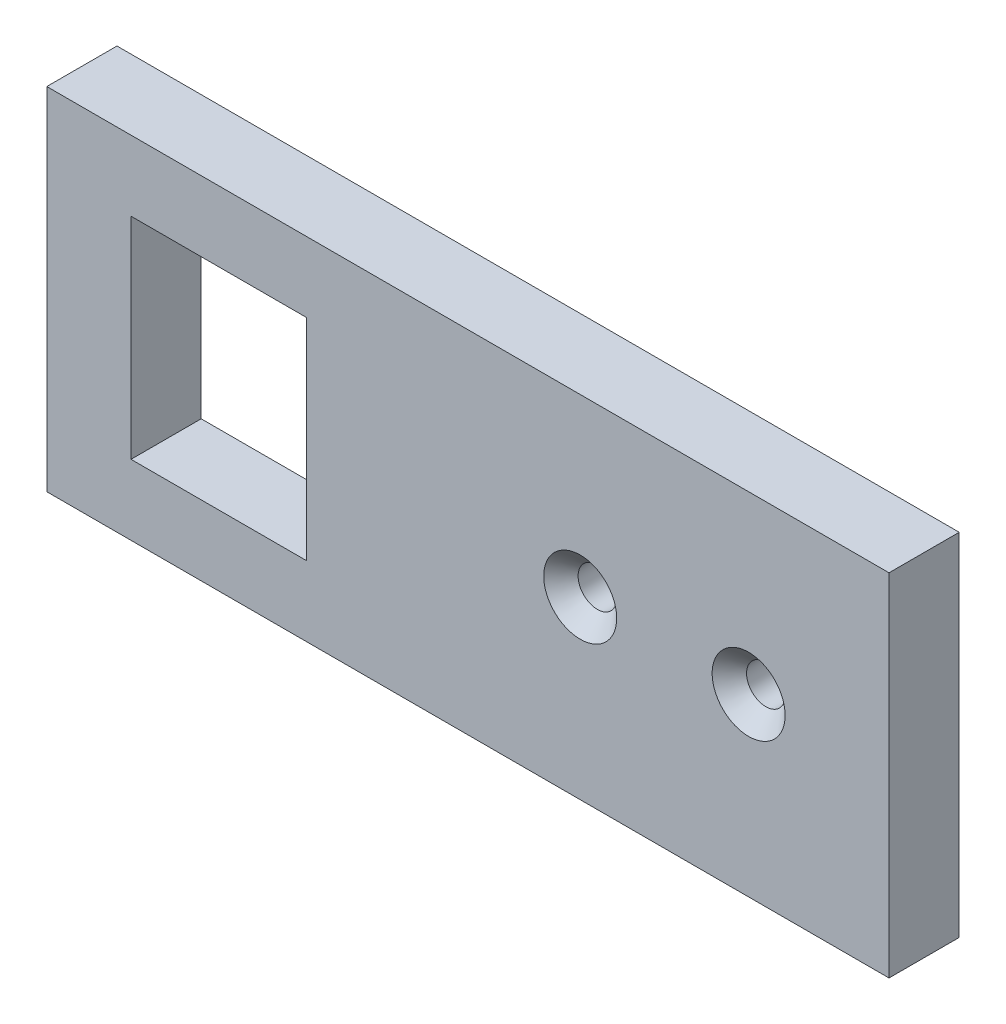
from build123d import *

# Parameters (mm, degrees)
ESQUISSE1_W                                         = 120
ESQUISSE1_H                                         = 50
BOSS_EXTRU_1_DEPTH                                  = 10
ESQUISSE2_W                                         = 25
ESQUISSE2_H                                         = 30
ENL_V_MAT_EXTRU_1_DEPTH                             = 10
CSK_FOR_M5_COUNTERSUNK_FLAT_HEAD_SCREW1_D           = 5.5
CSK_FOR_M5_COUNTERSUNK_FLAT_HEAD_SCREW1_CSINK_D     = 10.4
CSK_FOR_M5_COUNTERSUNK_FLAT_HEAD_SCREW1_CSINK_ANGLE = 90


with BuildPart() as part:
    # Esquisse1 → Boss.-Extru.1 (new body)
    with BuildSketch(Plane.XY):
        Rectangle(ESQUISSE1_W, ESQUISSE1_H)
    extrude(amount=BOSS_EXTRU_1_DEPTH)

    # Esquisse2 → Enlèv. mat.-Extru.1 (cut)
    with BuildSketch(Plane.XY.offset(10)):
        with Locations((-35.5, 0)):
            Rectangle(ESQUISSE2_W, ESQUISSE2_H)
    extrude(amount=-ENL_V_MAT_EXTRU_1_DEPTH, mode=Mode.SUBTRACT)

    # CSK for M5 Countersunk Flat Head Screw1 (through all)
    with Locations(Plane.XY.offset(10)):
        with Locations((16, 0), (40, 0)):
            CounterSinkHole(CSK_FOR_M5_COUNTERSUNK_FLAT_HEAD_SCREW1_D / 2, CSK_FOR_M5_COUNTERSUNK_FLAT_HEAD_SCREW1_CSINK_D / 2, counter_sink_angle=CSK_FOR_M5_COUNTERSUNK_FLAT_HEAD_SCREW1_CSINK_ANGLE)


solid = part.part
